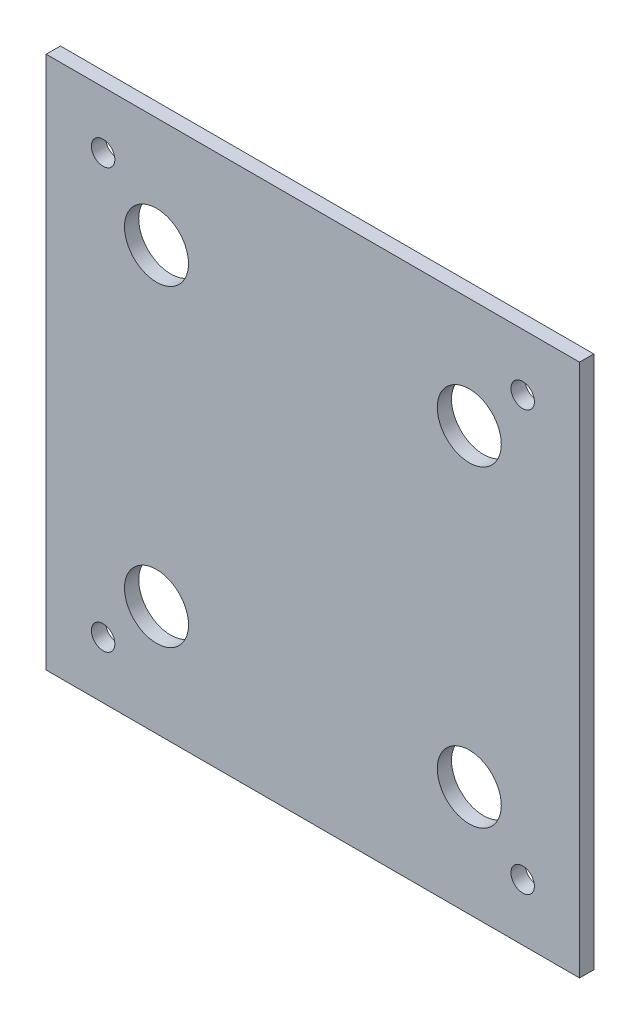
from build123d import *

# Parameters (mm, degrees)
SKETCH_1_W          = 75
SKETCH_1_H          = 75
EXTRUDE_1_DEPTH     = 2
M4X0_7_1_D          = 3.3
M4X0_7_1_DEPTH      = 11.5
M4X0_7_1_TIP        = 0.991420021
CUT_EXTRUDE_1_DEPTH = 80


with BuildPart() as part:
    # ｽｹｯﾁ1 → ﾎﾞｽ - 押し出し1 (new body)
    with BuildSketch(Plane.XY):
        Rectangle(SKETCH_1_W, SKETCH_1_H)
    extrude(amount=EXTRUDE_1_DEPTH)

    # M4x0.7 ねじ穴1
    with Locations(Plane(origin=(-29.5, -29.5, 0), x_dir=(-1, 0, 0), z_dir=(0, 0, -1))):
        with Locations((0, 0), (0, 59), (-59, 59), (-59, 0)):
            Hole(M4X0_7_1_D / 2, depth=M4X0_7_1_DEPTH)
            with Locations((0, 0, -(M4X0_7_1_DEPTH + M4X0_7_1_TIP / 2))):  # 118° drill point
                Cone(0, M4X0_7_1_D / 2, M4X0_7_1_TIP, mode=Mode.SUBTRACT)

    # ｽｹｯﾁ5 → ｶｯﾄ - 押し出し1 (cut)
    with BuildSketch(Plane(origin=(0, 0, 0), x_dir=(-1, 0, 0), z_dir=(0, 0, -1))):
        with BuildLine():
            ThreePointArc((21.991020895, -17.491020895), (18.80904038, -18.80904038), (17.491020895, -21.991020895))
            Line((17.491020895, -21.991020895), (21.991020895, -21.991020895))
            Line((21.991020895, -21.991020895), (21.991020895, -17.491020895))
        make_face()
        with BuildLine():
            Line((21.991020895, -21.991020895), (17.491020895, -21.991020895))
            ThreePointArc((17.491020895, -21.991020895), (21.991020895, -26.491020895), (26.491020895, -21.991020895))
            ThreePointArc((26.491020895, -21.991020895), (25.17300141, -18.80904038), (21.991020895, -17.491020895))
            Line((21.991020895, -17.491020895), (21.991020895, -21.991020895))
        make_face()
        with BuildLine():
            ThreePointArc((17.491020895, 21.991020895), (18.80904038, 18.80904038), (21.991020895, 17.491020895))
            Line((21.991020895, 17.491020895), (21.991020895, 21.991020895))
            Line((21.991020895, 21.991020895), (17.491020895, 21.991020895))
        make_face()
        with BuildLine():
            Line((21.991020895, 21.991020895), (21.991020895, 17.491020895))
            ThreePointArc((21.991020895, 17.491020895), (25.17300141, 18.80904038), (26.491020895, 21.991020895))
            ThreePointArc((26.491020895, 21.991020895), (21.991020895, 26.491020895), (17.491020895, 21.991020895))
            Line((17.491020895, 21.991020895), (21.991020895, 21.991020895))
        make_face()
        with BuildLine():
            ThreePointArc((-17.491020895, 21.991020895), (-25.17300141, 25.17300141), (-21.991020895, 17.491020895))
            Line((-21.991020895, 17.491020895), (-21.991020895, 21.991020895))
            Line((-21.991020895, 21.991020895), (-17.491020895, 21.991020895))
        make_face()
        with BuildLine():
            Line((-21.991020895, 21.991020895), (-21.991020895, 17.491020895))
            ThreePointArc((-21.991020895, 17.491020895), (-18.80904038, 18.80904038), (-17.491020895, 21.991020895))
            Line((-17.491020895, 21.991020895), (-21.991020895, 21.991020895))
        make_face()
        with BuildLine():
            Line((-17.491020895, -21.991020895), (-21.991020895, -21.991020895))
            Line((-21.991020895, -21.991020895), (-21.991020895, -17.491020895))
            ThreePointArc((-21.991020895, -17.491020895), (-25.17300141, -25.17300141), (-17.491020895, -21.991020895))
        make_face()
        with BuildLine():
            Line((-21.991020895, -21.991020895), (-18.80904038, -18.80904038))
            ThreePointArc((-18.80904038, -18.80904038), (-20.268945449, -17.833562999), (-21.991020895, -17.491020895))
            Line((-21.991020895, -17.491020895), (-21.991020895, -21.991020895))
        make_face()
        with BuildLine():
            ThreePointArc((-17.491020895, -21.991020895), (-17.833562999, -20.268945449), (-18.80904038, -18.80904038))
            Line((-18.80904038, -18.80904038), (-21.991020895, -21.991020895))
            Line((-21.991020895, -21.991020895), (-17.491020895, -21.991020895))
        make_face()
    extrude(amount=-CUT_EXTRUDE_1_DEPTH, mode=Mode.SUBTRACT)


solid = part.part
